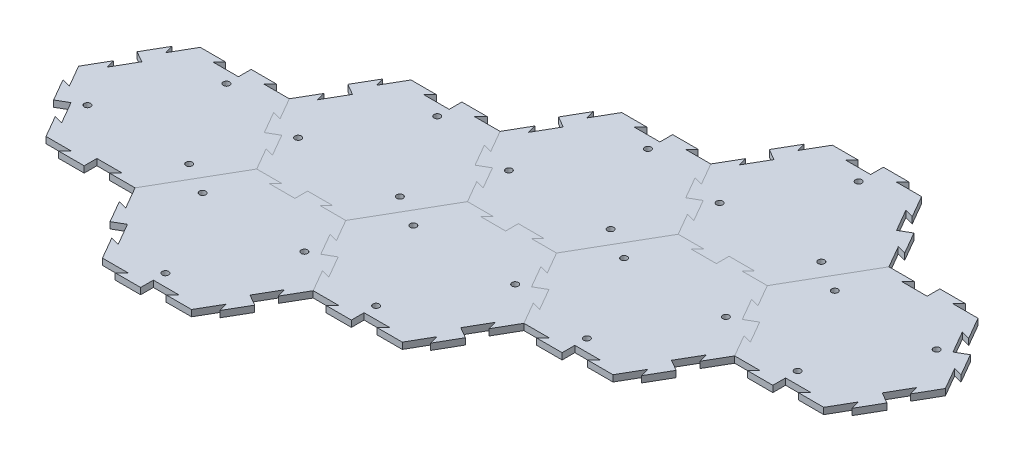
from build123d import *

# Parameters (mm, degrees)
BOSS_EXTRUDE1_DEPTH = 6.35
SKETCH9_R           = 3.175
CUT_EXTRUDE3_DEPTH  = 118.774954893
CIRPATTERN6_COUNT   = 3
CUT_EXTRUDE4_DEPTH  = 271.453350876
BOSS_EXTRUDE4_DEPTH = 6.35
CIRPATTERN7_COUNT   = 6
CUT_EXTRUDE5_DEPTH  = 271.453350876
BOSS_EXTRUDE5_DEPTH = 6.35
CIRPATTERN8_COUNT   = 6
LPATTERN1_COUNT     = 4
LPATTERN1_PITCH     = 153.979316882


with BuildPart() as part:
    # Sketch1 → Boss-Extrude1 (new body)
    with BuildSketch(Plane(origin=(0, 0, 0), x_dir=(1, 0, 0), z_dir=(0, 1, 0))):
        Polygon((88.9, 0), (44.45, 76.989658396), (-44.45, 76.989658396), (-88.9, 0), (-44.45, -76.989658396), (44.45, -76.989658396), align=None)
    extrude(amount=-BOSS_EXTRUDE1_DEPTH)

    # Sketch9 → Cut-Extrude3 (cut, through all)
    with BuildSketch(Plane(origin=(0, 0, 0), x_dir=(1, 0, 0), z_dir=(0, 1, 0))):
        with Locations((-50.8, -29.329393675)):
            Circle(SKETCH9_R)
    cut_extrude3 = extrude(amount=-CUT_EXTRUDE3_DEPTH, mode=Mode.SUBTRACT)

    # CirPattern6: Cut-Extrude3 ×3 about axis
    cirpattern6_axis = Axis((0, 0, 0), (0, 1, 0))
    for i in range(1, CIRPATTERN6_COUNT):
        add(cut_extrude3.rotate(cirpattern6_axis, i * 360 / CIRPATTERN6_COUNT), mode=Mode.SUBTRACT)


with BuildPart() as body_2:
    # Mirror3: mirrored copy
    add(part.part.mirror(Plane(origin=(44.45, -6.35, 76.989658396), x_dir=(-0.49999999999999495, 0, 0.8660254037844416), z_dir=(0.8660254037844416, 0, 0.49999999999999495))))

    # Sketch13 → Cut-Extrude5 (cut, through all)
    with BuildSketch(Plane(origin=(0, 0, 0), x_dir=(1, 0, 0), z_dir=(0, 1, 0))):
        Polygon((190.5, -21.997045256), (181.825738686, -19.672783942), (194.525738686, -41.669829198), (200.025, -38.494829198), align=None)
    cut_extrude5 = extrude(amount=-CUT_EXTRUDE5_DEPTH, mode=Mode.SUBTRACT)

    # Sketch14 → Boss-Extrude5 (add)
    with BuildSketch(Plane(origin=(0, 0, 0), x_dir=(1, 0, 0), z_dir=(0, 1, 0))):
        Polygon((200.025, -38.494829198), (205.524261314, -35.319829198), (218.224261314, -57.316874454), (209.55, -54.99261314), align=None)
    boss_extrude5 = extrude(amount=-BOSS_EXTRUDE5_DEPTH)

    # CirPattern8: Cut-Extrude5, Boss-Extrude5 ×6 about axis, 1 skipped
    cirpattern8_axis = Axis((133.35, 0, 76.989658396), (0, 1, 0))
    add([cut_extrude5.rotate(cirpattern8_axis, i * 360 / CIRPATTERN8_COUNT) for i in range(1, CIRPATTERN8_COUNT) if i not in (2,)], mode=Mode.SUBTRACT)
    add([boss_extrude5.rotate(cirpattern8_axis, i * 360 / CIRPATTERN8_COUNT) for i in range(1, CIRPATTERN8_COUNT) if i not in (2,)])


with BuildPart() as part_1:
    add(part.part)

    # Sketch10 → Cut-Extrude4 (cut, through all)
    with BuildSketch(Plane(origin=(0, 0, 0), x_dir=(1, 0, 0), z_dir=(0, 1, 0))):
        Polygon((57.15, 54.99261314), (48.475738686, 57.316874454), (61.175738686, 35.319829198), (66.675, 38.494829198), align=None)
    cut_extrude4 = extrude(amount=-CUT_EXTRUDE4_DEPTH, mode=Mode.SUBTRACT)

    # Sketch11 → Boss-Extrude4 (add)
    with BuildSketch(Plane(origin=(0, 0, 0), x_dir=(1, 0, 0), z_dir=(0, 1, 0))):
        Polygon((66.675, 38.494829198), (72.174261314, 41.669829198), (84.874261314, 19.672783942), (76.2, 21.997045256), align=None)
    boss_extrude4 = extrude(amount=-BOSS_EXTRUDE4_DEPTH)

    # CirPattern7: Cut-Extrude4, Boss-Extrude4 ×6 about axis, 1 skipped
    cirpattern7_axis = Axis((0, 0, 0), (0, 1, 0))
    add([cut_extrude4.rotate(cirpattern7_axis, i * 360 / CIRPATTERN7_COUNT) for i in range(1, CIRPATTERN7_COUNT) if i not in (5,)], mode=Mode.SUBTRACT)
    add([boss_extrude4.rotate(cirpattern7_axis, i * 360 / CIRPATTERN7_COUNT) for i in range(1, CIRPATTERN7_COUNT) if i not in (5,)])


with BuildPart() as lpattern1_1:
    # LPattern1: pattern copy
    add(part_1.part.moved(Location(Vector(0.8660254037844385, 0, -0.5000000000000003) * (1 * LPATTERN1_PITCH))))


with BuildPart() as lpattern1_2:
    # LPattern1: pattern copy
    add(part_1.part.moved(Location(Vector(0.8660254037844385, 0, -0.5000000000000003) * (2 * LPATTERN1_PITCH))))


with BuildPart() as lpattern1_3:
    # LPattern1: pattern copy
    add(part_1.part.moved(Location(Vector(0.8660254037844385, 0, -0.5000000000000003) * (3 * LPATTERN1_PITCH))))


with BuildPart() as lpattern1_4:
    # LPattern1: pattern copy
    add(body_2.part.moved(Location(Vector(0.8660254037844385, 0, -0.5000000000000003) * (1 * LPATTERN1_PITCH))))


with BuildPart() as lpattern1_5:
    # LPattern1: pattern copy
    add(body_2.part.moved(Location(Vector(0.8660254037844385, 0, -0.5000000000000003) * (2 * LPATTERN1_PITCH))))


with BuildPart() as lpattern1_6:
    # LPattern1: pattern copy
    add(body_2.part.moved(Location(Vector(0.8660254037844385, 0, -0.5000000000000003) * (3 * LPATTERN1_PITCH))))


solid = Compound([body_2.part, part_1.part, lpattern1_1.part, lpattern1_2.part, lpattern1_3.part, lpattern1_4.part, lpattern1_5.part, lpattern1_6.part])
